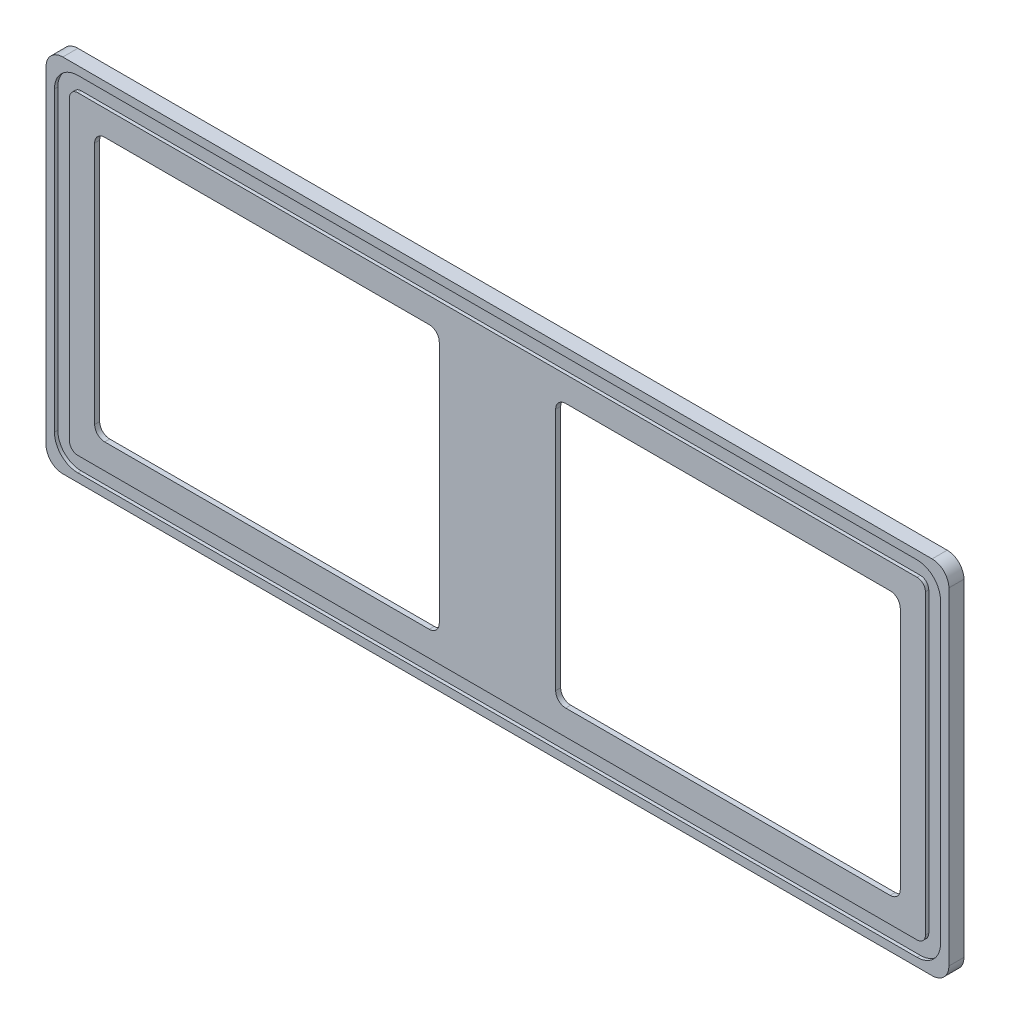
from build123d import *

# Parameters (mm, degrees)
BOSS_EXTRUDE1_DEPTH = 9
CUT_EXTRUDE1_DEPTH  = 2
CUT_EXTRUDE2_DEPTH  = 9
CUT_EXTRUDE4_DEPTH  = 6


with BuildPart() as part:
    # Sketch1 → Boss-Extrude1 (new body)
    with BuildSketch(Plane.XY):
        with BuildLine():
            Line((259.35, -9), (-259.35, -9))
            ThreePointArc((-259.35, -9), (-266.421067812, -6.071067812), (-269.35, 1))
            Line((-269.35, 1), (-269.35, 196.4))
            ThreePointArc((-269.35, 196.4), (-266.421067812, 203.471067812), (-259.35, 206.4))
            Line((-259.35, 206.4), (259.35, 206.4))
            ThreePointArc((259.35, 206.4), (266.421067812, 203.471067812), (269.35, 196.4))
            Line((269.35, 196.4), (269.35, 1))
            ThreePointArc((269.35, 1), (266.421067812, -6.071067812), (259.35, -9))
        make_face()
    extrude(amount=BOSS_EXTRUDE1_DEPTH)

    # Sketch4 → Cut-Extrude1 (cut)
    with BuildSketch(Plane.XY.offset(9)):
        with BuildLine():
            Line((-250.35, -4), (250.35, -4))
            ThreePointArc((250.35, -4), (260.249494937, 0.100505063), (264.35, 10))
            Line((264.35, 10), (264.35, 187.4))
            ThreePointArc((264.35, 187.4), (260.249494937, 197.299494937), (250.35, 201.4))
            Line((250.35, 201.4), (-250.35, 201.4))
            ThreePointArc((-250.35, 201.4), (-260.249494937, 197.299494937), (-264.35, 187.4))
            Line((-264.35, 187.4), (-264.35, 10))
            ThreePointArc((-264.35, 10), (-260.249494937, 0.100505063), (-250.35, -4))
        make_face()
        with BuildLine():
            Line((-250.35, 5), (250.35, 5))
            ThreePointArc((250.35, 5), (253.885533906, 6.464466094), (255.35, 10))
            Line((255.35, 10), (255.35, 187.4))
            ThreePointArc((255.35, 187.4), (253.885533906, 190.935533906), (250.35, 192.4))
            Line((250.35, 192.4), (-250.35, 192.4))
            ThreePointArc((-250.35, 192.4), (-253.885533906, 190.935533906), (-255.35, 187.4))
            Line((-255.35, 187.4), (-255.35, 10))
            ThreePointArc((-255.35, 10), (-253.885533906, 6.464466094), (-250.35, 5))
        make_face(mode=Mode.SUBTRACT)
    extrude(amount=-CUT_EXTRUDE1_DEPTH, mode=Mode.SUBTRACT)

    # Sketch5 → Cut-Extrude2 (cut)
    with BuildSketch(Plane.XY):
        with BuildLine():
            Line((-234.35, 177.4), (-40.731266216, 177.4))
            ThreePointArc((-40.731266216, 177.4), (-36.488625529, 175.642640687), (-34.731266216, 171.4))
            Line((-34.731266216, 171.4), (-34.731266216, 26))
            ThreePointArc((-34.731266216, 26), (-36.488625529, 21.757359313), (-40.731266216, 20))
            Line((-40.731266216, 20), (-234.35, 20))
            ThreePointArc((-234.35, 20), (-238.592640687, 21.757359313), (-240.35, 26))
            Line((-240.35, 26), (-240.35, 171.4))
            ThreePointArc((-240.35, 171.4), (-238.592640687, 175.642640687), (-234.35, 177.4))
        make_face()
    cut_extrude2 = extrude(amount=CUT_EXTRUDE2_DEPTH, mode=Mode.SUBTRACT)

    # Sketch7 → Cut-Extrude4 (cut)
    with BuildSketch(Plane(origin=(0, 0, 0), x_dir=(-1, 0, 0), z_dir=(0, 0, -1))):
        with BuildLine():
            Line((250.35, 26), (250.35, 171.4))
            ThreePointArc((250.35, 171.4), (245.663708499, 182.713708499), (234.35, 187.4))
            Line((234.35, 187.4), (40.731266216, 187.4))
            ThreePointArc((40.731266216, 187.4), (29.417557717, 182.713708499), (24.731266216, 171.4))
            Line((24.731266216, 171.4), (24.731266216, 26))
            ThreePointArc((24.731266216, 26), (29.417557717, 14.686291501), (40.731266216, 10))
            Line((40.731266216, 10), (234.35, 10))
            ThreePointArc((234.35, 10), (245.663708499, 14.686291501), (250.35, 26))
        make_face()
    cut_extrude4 = extrude(amount=-CUT_EXTRUDE4_DEPTH, mode=Mode.SUBTRACT)

    # Mirror1: Cut-Extrude2, Cut-Extrude4 across plane
    add(cut_extrude2.mirror(Plane(origin=(0, 0, 0), x_dir=(0, 0, 1), z_dir=(1, 0, 0))), mode=Mode.SUBTRACT)
    add(cut_extrude4.mirror(Plane(origin=(0, 0, 0), x_dir=(0, 0, 1), z_dir=(1, 0, 0))), mode=Mode.SUBTRACT)


solid = part.part
